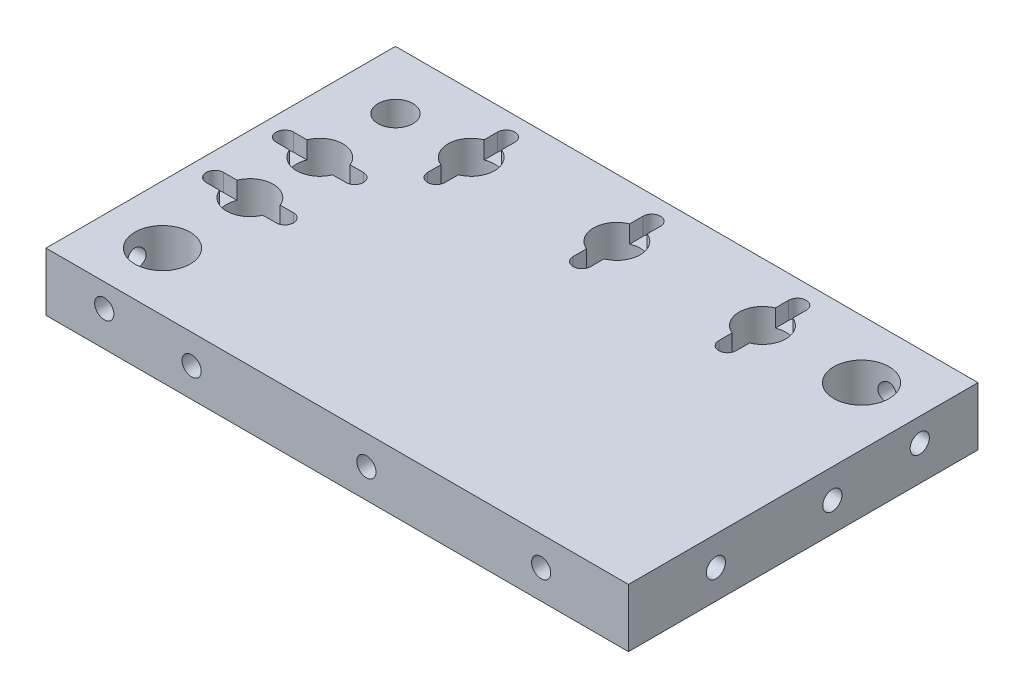
from build123d import *

# Parameters (mm, degrees)
SKETCH1_W             = 100
SKETCH1_H             = 60
BOSS_EXTRUDE1_DEPTH   = 10
CUT_EXTRUDE1_REACH    = 12
SKETCH2_R             = 3
SKETCH2_R_2           = 4
SKETCH2_R_3           = 4.75
CUT_EXTRUDE2_DEPTH    = 3
M4_TAPPED_HOLE1_D     = 3.3
M4_TAPPED_HOLE1_DEPTH = 12
M4_TAPPED_HOLE1_TIP   = 0.991420021
M4_TAPPED_HOLE2_D     = 3.3
M4_TAPPED_HOLE2_DEPTH = 12
M4_TAPPED_HOLE2_TIP   = 0.991420021
M4_TAPPED_HOLE3_D     = 3.3
M4_TAPPED_HOLE3_DEPTH = 12
M4_TAPPED_HOLE3_TIP   = 0.991420021
M4_TAPPED_HOLE4_D     = 3.3
M4_TAPPED_HOLE4_DEPTH = 12
M4_TAPPED_HOLE4_TIP   = 0.991420021


with BuildPart() as part:
    # Sketch1 → Boss-Extrude1 (new body)
    with BuildSketch(Plane(origin=(0, 0, 0), x_dir=(1, 0, 0), z_dir=(0, 1, 0))):
        Rectangle(SKETCH1_W, SKETCH1_H)
    extrude(amount=BOSS_EXTRUDE1_DEPTH)

    # Sketch2 → Cut-Extrude1 (cut, up to next)
    with BuildSketch(Plane(origin=(0, 10, 0), x_dir=(1, 0, 0), z_dir=(0, 1, 0)), mode=Mode.PRIVATE) as cut_extrude1_sk1:
        with Locations((-40, 20)):
            Circle(SKETCH2_R)
    cut_extrude1_tool1 = extrude(cut_extrude1_sk1.sketch, amount=-CUT_EXTRUDE1_REACH, mode=Mode.PRIVATE) & part.part
    add(cut_extrude1_tool1.solids().sort_by_distance((-40, 10, -20))[0], mode=Mode.SUBTRACT)
    # Sketch2 → Cut-Extrude1 (cut, up to next)
    with BuildSketch(Plane(origin=(0, 10, 0), x_dir=(1, 0, 0), z_dir=(0, 1, 0)), mode=Mode.PRIVATE) as cut_extrude1_sk2:
        with Locations((-27, 20)):
            Circle(SKETCH2_R_2)
    cut_extrude1_tool2 = extrude(cut_extrude1_sk2.sketch, amount=-CUT_EXTRUDE1_REACH, mode=Mode.PRIVATE) & part.part
    add(cut_extrude1_tool2.solids().sort_by_distance((-27, 10, -20))[0], mode=Mode.SUBTRACT)
    # Sketch2 → Cut-Extrude1 (cut, up to next)
    with BuildSketch(Plane(origin=(0, 10, 0), x_dir=(1, 0, 0), z_dir=(0, 1, 0)), mode=Mode.PRIVATE) as cut_extrude1_sk3:
        with Locations((-2, 20)):
            Circle(SKETCH2_R_2)
    cut_extrude1_tool3 = extrude(cut_extrude1_sk3.sketch, amount=-CUT_EXTRUDE1_REACH, mode=Mode.PRIVATE) & part.part
    add(cut_extrude1_tool3.solids().sort_by_distance((-2, 10, -20))[0], mode=Mode.SUBTRACT)
    # Sketch2 → Cut-Extrude1 (cut, up to next)
    with BuildSketch(Plane(origin=(0, 10, 0), x_dir=(1, 0, 0), z_dir=(0, 1, 0)), mode=Mode.PRIVATE) as cut_extrude1_sk4:
        with Locations((23, 20)):
            Circle(SKETCH2_R_2)
    cut_extrude1_tool4 = extrude(cut_extrude1_sk4.sketch, amount=-CUT_EXTRUDE1_REACH, mode=Mode.PRIVATE) & part.part
    add(cut_extrude1_tool4.solids().sort_by_distance((23, 10, -20))[0], mode=Mode.SUBTRACT)
    # Sketch2 → Cut-Extrude1 (cut, up to next)
    with BuildSketch(Plane(origin=(0, 10, 0), x_dir=(1, 0, 0), z_dir=(0, 1, 0)), mode=Mode.PRIVATE) as cut_extrude1_sk5:
        with Locations((40, 20)):
            Circle(SKETCH2_R_3)
    cut_extrude1_tool5 = extrude(cut_extrude1_sk5.sketch, amount=-CUT_EXTRUDE1_REACH, mode=Mode.PRIVATE) & part.part
    add(cut_extrude1_tool5.solids().sort_by_distance((40, 10, -20))[0], mode=Mode.SUBTRACT)
    # Sketch2 → Cut-Extrude1 (cut, up to next)
    with BuildSketch(Plane(origin=(0, 10, 0), x_dir=(1, 0, 0), z_dir=(0, 1, 0)), mode=Mode.PRIVATE) as cut_extrude1_sk6:
        with Locations((-40, 7)):
            Circle(SKETCH2_R_2)
    cut_extrude1_tool6 = extrude(cut_extrude1_sk6.sketch, amount=-CUT_EXTRUDE1_REACH, mode=Mode.PRIVATE) & part.part
    add(cut_extrude1_tool6.solids().sort_by_distance((-40, 10, -7))[0], mode=Mode.SUBTRACT)
    # Sketch2 → Cut-Extrude1 (cut, up to next)
    with BuildSketch(Plane(origin=(0, 10, 0), x_dir=(1, 0, 0), z_dir=(0, 1, 0)), mode=Mode.PRIVATE) as cut_extrude1_sk7:
        with Locations((-40, -5)):
            Circle(SKETCH2_R_2)
    cut_extrude1_tool7 = extrude(cut_extrude1_sk7.sketch, amount=-CUT_EXTRUDE1_REACH, mode=Mode.PRIVATE) & part.part
    add(cut_extrude1_tool7.solids().sort_by_distance((-40, 10, 5))[0], mode=Mode.SUBTRACT)
    # Sketch2 → Cut-Extrude1 (cut, up to next)
    with BuildSketch(Plane(origin=(0, 10, 0), x_dir=(1, 0, 0), z_dir=(0, 1, 0)), mode=Mode.PRIVATE) as cut_extrude1_sk8:
        with Locations((-40, -20)):
            Circle(SKETCH2_R_3)
    cut_extrude1_tool8 = extrude(cut_extrude1_sk8.sketch, amount=-CUT_EXTRUDE1_REACH, mode=Mode.PRIVATE) & part.part
    add(cut_extrude1_tool8.solids().sort_by_distance((-40, 10, 20))[0], mode=Mode.SUBTRACT)

    # Sketch3 → Cut-Extrude2 (cut)
    with BuildSketch(Plane(origin=(0, 10, 0), x_dir=(1, 0, 0), z_dir=(0, 1, 0))):
        with BuildLine():
            Line((-46, 8.5), (-34, 8.5))
            ThreePointArc((-34, 8.5), (-32.5, 7), (-34, 5.5))
            Line((-34, 5.5), (-46, 5.5))
            ThreePointArc((-46, 5.5), (-47.5, 7), (-46, 8.5))
        make_face()
        with BuildLine():
            Line((-46, -3.5), (-34, -3.5))
            ThreePointArc((-34, -3.5), (-32.5, -5), (-34, -6.5))
            Line((-34, -6.5), (-46, -6.5))
            ThreePointArc((-46, -6.5), (-47.5, -5), (-46, -3.5))
        make_face()
        with BuildLine():
            Line((-25.5, 26), (-25.5, 14))
            ThreePointArc((-25.5, 14), (-27, 12.5), (-28.5, 14))
            Line((-28.5, 14), (-28.5, 26))
            ThreePointArc((-28.5, 26), (-27, 27.5), (-25.5, 26))
        make_face()
        with BuildLine():
            Line((-0.5, 26), (-0.5, 14))
            ThreePointArc((-0.5, 14), (-2, 12.5), (-3.5, 14))
            Line((-3.5, 14), (-3.5, 26))
            ThreePointArc((-3.5, 26), (-2, 27.5), (-0.5, 26))
        make_face()
        with BuildLine():
            Line((24.5, 26), (24.5, 14))
            ThreePointArc((24.5, 14), (23, 12.5), (21.5, 14))
            Line((21.5, 14), (21.5, 26))
            ThreePointArc((21.5, 26), (23, 27.5), (24.5, 26))
        make_face()
    extrude(amount=-CUT_EXTRUDE2_DEPTH, mode=Mode.SUBTRACT)

    # M4 Tapped Hole1
    with Locations(Plane.ZY.offset(50)):
        with Locations((20, 6)):
            Hole(M4_TAPPED_HOLE1_D / 2, depth=M4_TAPPED_HOLE1_DEPTH)
            with Locations((0, 0, -(M4_TAPPED_HOLE1_DEPTH + M4_TAPPED_HOLE1_TIP / 2))):  # 118° drill point
                Cone(0, M4_TAPPED_HOLE1_D / 2, M4_TAPPED_HOLE1_TIP, mode=Mode.SUBTRACT)

    # M4 Tapped Hole2
    with Locations(Plane.XY.offset(30)):
        with Locations((-40, 6), (-25, 5), (5, 5), (35, 5)):
            Hole(M4_TAPPED_HOLE2_D / 2, depth=M4_TAPPED_HOLE2_DEPTH)
            with Locations((0, 0, -(M4_TAPPED_HOLE2_DEPTH + M4_TAPPED_HOLE2_TIP / 2))):  # 118° drill point
                Cone(0, M4_TAPPED_HOLE2_D / 2, M4_TAPPED_HOLE2_TIP, mode=Mode.SUBTRACT)

    # M4 Tapped Hole3
    with Locations(Plane(origin=(50, 0, 0), x_dir=(0, 0, -1), z_dir=(1, 0, 0))):
        with Locations((-15, 5), (5, 5), (20, 6)):
            Hole(M4_TAPPED_HOLE3_D / 2, depth=M4_TAPPED_HOLE3_DEPTH)
            with Locations((0, 0, -(M4_TAPPED_HOLE3_DEPTH + M4_TAPPED_HOLE3_TIP / 2))):  # 118° drill point
                Cone(0, M4_TAPPED_HOLE3_D / 2, M4_TAPPED_HOLE3_TIP, mode=Mode.SUBTRACT)

    # M4 Tapped Hole4
    with Locations(Plane(origin=(0, 0, -30), x_dir=(-1, 0, 0), z_dir=(0, 0, -1))):
        with Locations((-40, 6)):
            Hole(M4_TAPPED_HOLE4_D / 2, depth=M4_TAPPED_HOLE4_DEPTH)
            with Locations((0, 0, -(M4_TAPPED_HOLE4_DEPTH + M4_TAPPED_HOLE4_TIP / 2))):  # 118° drill point
                Cone(0, M4_TAPPED_HOLE4_D / 2, M4_TAPPED_HOLE4_TIP, mode=Mode.SUBTRACT)


solid = part.part
